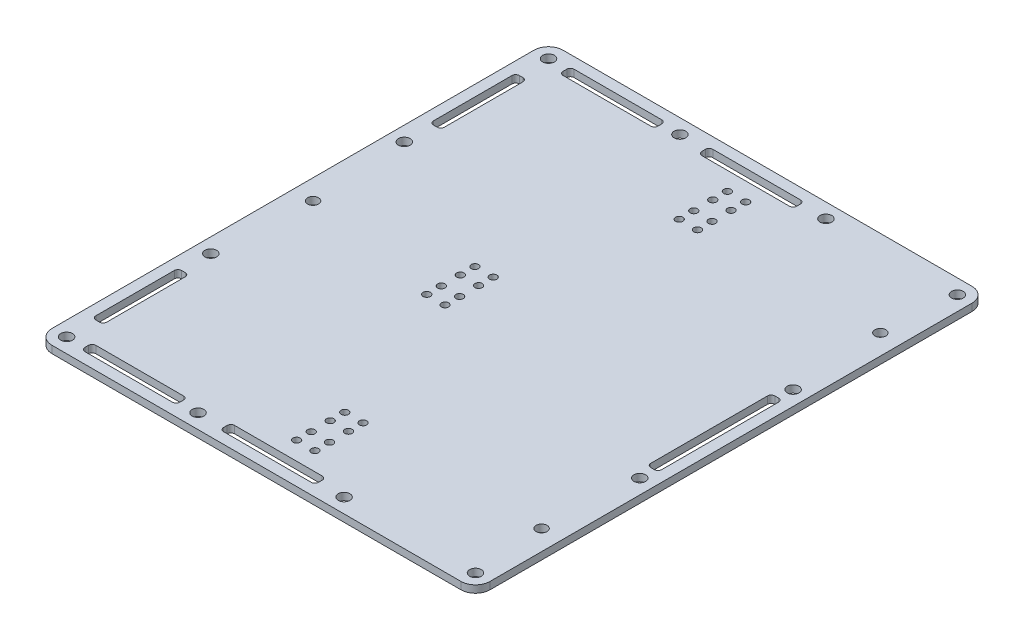
from build123d import *

# Parameters (mm, degrees)
SKETCH1_W           = 120
SKETCH1_H           = 140
BOSS_EXTRUDE1_DEPTH = 4
SKETCH20_W          = 20
SKETCH20_H          = 3
BOSS_EXTRUDE5_DEPTH = 8
SKETCH25_R          = 1.6
CUT_EXTRUDE21_DEPTH = 142.061724079
CUT_EXTRUDE22_DEPTH = 10
SKETCH15_R          = 1.6
CUT_EXTRUDE24_DEPTH = 93.54188241
SKETCH28_W          = 120
SKETCH28_H          = 12
CUT_EXTRUDE25_DEPTH = 153.787434038
SKETCH26_W          = 20
SKETCH26_H          = 62
SKETCH26_H_2        = 27
BOSS_EXTRUDE6_DEPTH = 8
CUT_EXTRUDE32_DEPTH = 30
CUT_EXTRUDE33_DEPTH = 30
SKETCH30_R          = 1
CUT_EXTRUDE34_DEPTH = 93.736184955
CUT_EXTRUDE35_DEPTH = 118.749734607
SKETCH33_W          = 20
SKETCH33_H          = 10.5
SKETCH33_H_2        = 29
CUT_EXTRUDE36_DEPTH = 8
CUT_EXTRUDE37_DEPTH = 93.736184955
FILLET1_R           = 0.5
SKETCH35_R          = 1.5
CUT_EXTRUDE38_DEPTH = 10


with BuildPart() as part:
    # Sketch1 → Boss-Extrude1 (new body)
    with BuildSketch(Plane(origin=(0, 0, 0), x_dir=(1, 0, 0), z_dir=(0, 1, 0))):
        Rectangle(SKETCH1_W, SKETCH1_H)
    extrude(amount=BOSS_EXTRUDE1_DEPTH)

    # Sketch20 → Boss-Extrude5 (add)
    with BuildSketch(Plane(origin=(0, 4, 0), x_dir=(1, 0, 0), z_dir=(0, 1, 0))):
        with Locations((-42.5, -55.6)):
            Rectangle(SKETCH20_W, SKETCH20_H)
        with Locations((-42.5, -35.6)):
            Rectangle(SKETCH20_W, SKETCH20_H)
        with Locations((42.5, -10)):
            Rectangle(SKETCH20_W, SKETCH20_H)
        with Locations((42.5, 10)):
            Rectangle(SKETCH20_W, SKETCH20_H)
        with Locations((-42.5, 55.6)):
            Rectangle(SKETCH20_W, SKETCH20_H)
        with Locations((-42.5, 35.6)):
            Rectangle(SKETCH20_W, SKETCH20_H)
    extrude(amount=BOSS_EXTRUDE5_DEPTH)

    # Sketch25 → Cut-Extrude21 (cut, through all)
    with BuildSketch(Plane.XY.offset(57.1)):
        with Locations((-47.5, 8)):
            Circle(SKETCH25_R)
        with Locations((-37.5, 8)):
            Circle(SKETCH25_R)
        with Locations((37.5, 8)):
            Circle(SKETCH25_R)
        with Locations((47.5, 8)):
            Circle(SKETCH25_R)
    extrude(amount=-CUT_EXTRUDE21_DEPTH, mode=Mode.SUBTRACT)

    # Sketch9 → Cut-Extrude22 (cut)
    with BuildSketch(Plane(origin=(0, 4, 0), x_dir=(1, 0, 0), z_dir=(0, 1, 0))):
        with BuildLine():
            Line((-60, -70), (-56, -70))
            ThreePointArc((-56, -70), (-58.828427125, -68.828427125), (-60, -66))
            Line((-60, -66), (-60, -70))
        make_face()
        with BuildLine():
            ThreePointArc((60, -66), (58.828427125, -68.828427125), (56, -70))
            Line((56, -70), (60, -70))
            Line((60, -70), (60, -66))
        make_face()
        with BuildLine():
            Line((-60, 70), (-60, 66))
            ThreePointArc((-60, 66), (-58.828427125, 68.828427125), (-56, 70))
            Line((-56, 70), (-60, 70))
        make_face()
        with BuildLine():
            ThreePointArc((56, 70), (58.828427125, 68.828427125), (60, 66))
            Line((60, 66), (60, 70))
            Line((60, 70), (56, 70))
        make_face()
    extrude(amount=-CUT_EXTRUDE22_DEPTH, mode=Mode.SUBTRACT)

    # Sketch15 → Cut-Extrude24 (cut, through all)
    with BuildSketch(Plane(origin=(0, 4, 0), x_dir=(1, 0, 0), z_dir=(0, 1, 0))):
        with Locations((-56, 66)):
            Circle(SKETCH15_R)
        with Locations((-56, -66)):
            Circle(SKETCH15_R)
        with Locations((56, -66)):
            Circle(SKETCH15_R)
        with Locations((56, 66)):
            Circle(SKETCH15_R)
        with Locations((-56, -26.5)):
            Circle(SKETCH15_R)
        with Locations((-56, 26.5)):
            Circle(SKETCH15_R)
        with Locations((20, 66)):
            Circle(SKETCH15_R)
        with Locations((-20, 66)):
            Circle(SKETCH15_R)
        with Locations((-20, -66)):
            Circle(SKETCH15_R)
        with Locations((20, -66)):
            Circle(SKETCH15_R)
        with Locations((56, -21)):
            Circle(SKETCH15_R)
        with Locations((56, 21)):
            Circle(SKETCH15_R)
    extrude(amount=-CUT_EXTRUDE24_DEPTH, mode=Mode.SUBTRACT)

    # Sketch28 → Cut-Extrude25 (cut, through all)
    with BuildSketch(Plane.XY.offset(70)):
        with Locations((0, 8)):
            Rectangle(SKETCH28_W, SKETCH28_H)
    extrude(amount=-CUT_EXTRUDE25_DEPTH, mode=Mode.SUBTRACT)

    # Sketch26 → Boss-Extrude6 (add)
    with BuildSketch(Plane.XZ):
        with Locations((35, 0)):
            Rectangle(SKETCH26_W, SKETCH26_H)
        with Locations((5, 0)):
            Rectangle(SKETCH26_W, SKETCH26_H)
        with Locations((-40, 38.5)):
            Rectangle(SKETCH26_W, SKETCH26_H_2)
        with Locations((-25, -38.5)):
            Rectangle(SKETCH26_W, SKETCH26_H_2)
    extrude(amount=BOSS_EXTRUDE6_DEPTH)

    # Sketch31 → Cut-Extrude32 (cut)
    with BuildSketch(Plane(origin=(0, 0, -52), x_dir=(-1, 0, 0), z_dir=(0, 0, -1))):
        with BuildLine():
            Line((17.7, -4.4), (17.7, -3.4))
            ThreePointArc((17.7, -3.4), (19.9, -1.2), (22.1, -3.4))
            Line((22.1, -3.4), (22.1, -4.4))
            ThreePointArc((22.1, -4.4), (19.9, -6.6), (17.7, -4.4))
        make_face()
        with BuildLine():
            Line((27.9, -4.4), (27.9, -3.4))
            ThreePointArc((27.9, -3.4), (30.1, -1.2), (32.3, -3.4))
            Line((32.3, -3.4), (32.3, -4.4))
            ThreePointArc((32.3, -4.4), (30.1, -6.6), (27.9, -4.4))
        make_face()
    extrude(amount=-CUT_EXTRUDE32_DEPTH, mode=Mode.SUBTRACT)

    # Sketch32 → Cut-Extrude33 (cut)
    with BuildSketch(Plane.XY.offset(52)):
        with BuildLine():
            Line((-47.3, -4.4), (-47.3, -3.4))
            ThreePointArc((-47.3, -3.4), (-45.1, -1.2), (-42.9, -3.4))
            Line((-42.9, -3.4), (-42.9, -4.4))
            ThreePointArc((-42.9, -4.4), (-45.1, -6.6), (-47.3, -4.4))
        make_face()
        with BuildLine():
            Line((-37.1, -4.4), (-37.1, -3.4))
            ThreePointArc((-37.1, -3.4), (-34.9, -1.2), (-32.7, -3.4))
            Line((-32.7, -3.4), (-32.7, -4.4))
            ThreePointArc((-32.7, -4.4), (-34.9, -6.6), (-37.1, -4.4))
        make_face()
    extrude(amount=-CUT_EXTRUDE33_DEPTH, mode=Mode.SUBTRACT)

    # Sketch30 → Cut-Extrude34 (cut, through all)
    with BuildSketch(Plane(origin=(0, 2, 0), x_dir=(1, 0, 0), z_dir=(0, 1, 0))):
        with Locations((5, 59)):
            Circle(SKETCH30_R)
        with Locations((5, 49.8)):
            Circle(SKETCH30_R)
        with Locations((5, 45.8)):
            Circle(SKETCH30_R)
        with Locations((5, 55)):
            Circle(SKETCH30_R)
        with Locations((5, -49.8)):
            Circle(SKETCH30_R)
        with Locations((5, -55)):
            Circle(SKETCH30_R)
        with Locations((5, -45.8)):
            Circle(SKETCH30_R)
        with Locations((5, -59)):
            Circle(SKETCH30_R)
        with Locations((0, -49.8)):
            Circle(SKETCH30_R)
        with Locations((0, -55)):
            Circle(SKETCH30_R)
        with Locations((0, -45.8)):
            Circle(SKETCH30_R)
        with Locations((0, -59)):
            Circle(SKETCH30_R)
        with Locations((0, 59)):
            Circle(SKETCH30_R)
        with Locations((0, 45.8)):
            Circle(SKETCH30_R)
        with Locations((0, 55)):
            Circle(SKETCH30_R)
        with Locations((0, 49.8)):
            Circle(SKETCH30_R)
        with Locations((-11.75, 2.6)):
            Circle(SKETCH30_R)
        with Locations((-11.75, -2.6)):
            Circle(SKETCH30_R)
        with Locations((-11.75, 6.6)):
            Circle(SKETCH30_R)
        with Locations((-11.75, -6.6)):
            Circle(SKETCH30_R)
        with Locations((-16.75, 2.6)):
            Circle(SKETCH30_R)
        with Locations((-16.75, -2.6)):
            Circle(SKETCH30_R)
        with Locations((-16.75, 6.6)):
            Circle(SKETCH30_R)
        with Locations((-16.75, -6.6)):
            Circle(SKETCH30_R)
    extrude(amount=-CUT_EXTRUDE34_DEPTH, mode=Mode.SUBTRACT)

    # Sketch29 → Cut-Extrude35 (cut, through all)
    with BuildSketch(Plane(origin=(0, 0, -31), x_dir=(-1, 0, 0), z_dir=(0, 0, -1))):
        with BuildLine():
            Line((-7.9, -3.4), (-7.9, -4.4))
            ThreePointArc((-7.9, -4.4), (-10.1, -6.6), (-12.3, -4.4))
            Line((-12.3, -4.4), (-12.3, -3.4))
            ThreePointArc((-12.3, -3.4), (-10.1, -1.2), (-7.9, -3.4))
        make_face()
        with BuildLine():
            Line((-37.9, -3.4), (-37.9, -4.4))
            ThreePointArc((-37.9, -4.4), (-40.1, -6.6), (-42.3, -4.4))
            Line((-42.3, -4.4), (-42.3, -3.4))
            ThreePointArc((-42.3, -3.4), (-40.1, -1.2), (-37.9, -3.4))
        make_face()
        with BuildLine():
            Line((-27.7, -3.4), (-27.7, -4.4))
            ThreePointArc((-27.7, -4.4), (-29.9, -6.6), (-32.1, -4.4))
            Line((-32.1, -4.4), (-32.1, -3.4))
            ThreePointArc((-32.1, -3.4), (-29.9, -1.2), (-27.7, -3.4))
        make_face()
        with BuildLine():
            Line((2.3, -3.4), (2.3, -4.4))
            ThreePointArc((2.3, -4.4), (0.1, -6.6), (-2.1, -4.4))
            Line((-2.1, -4.4), (-2.1, -3.4))
            ThreePointArc((-2.1, -3.4), (0.1, -1.2), (2.3, -3.4))
        make_face()
    extrude(amount=-CUT_EXTRUDE35_DEPTH, mode=Mode.SUBTRACT)

    # Sketch33 → Cut-Extrude36 (cut)
    with BuildSketch(Plane.XZ.offset(8)):
        with Locations((-25, -46.75)):
            Rectangle(SKETCH33_W, SKETCH33_H)
        with Locations((35, 0)):
            Rectangle(SKETCH33_W, SKETCH33_H_2)
    extrude(amount=-CUT_EXTRUDE36_DEPTH, mode=Mode.SUBTRACT)

    # Sketch34 → Cut-Extrude37 (cut, through all)
    with BuildSketch(Plane(origin=(0, 2, 0), x_dir=(1, 0, 0), z_dir=(0, 1, 0))):
        with BuildLine():
            Line((-50, -64), (-26, -64))
            ThreePointArc((-26, -64), (-25.292893219, -64.292893219), (-25, -65))
            Line((-25, -65), (-25, -66))
            ThreePointArc((-25, -66), (-25.292893219, -66.707106781), (-26, -67))
            Line((-26, -67), (-50, -67))
            ThreePointArc((-50, -67), (-50.707106781, -66.707106781), (-51, -66))
            Line((-51, -66), (-51, -65))
            ThreePointArc((-51, -65), (-50.707106781, -64.292893219), (-50, -64))
        make_face()
        with BuildLine():
            Line((-56, -34.5), (-55, -34.5))
            ThreePointArc((-55, -34.5), (-54.292893219, -34.792893219), (-54, -35.5))
            Line((-54, -35.5), (-54, -57))
            ThreePointArc((-54, -57), (-54.292893219, -57.707106781), (-55, -58))
            Line((-55, -58), (-56, -58))
            ThreePointArc((-56, -58), (-56.707106781, -57.707106781), (-57, -57))
            Line((-57, -57), (-57, -35.5))
            ThreePointArc((-57, -35.5), (-56.707106781, -34.792893219), (-56, -34.5))
        make_face()
        with BuildLine():
            Line((-12, -64), (12, -64))
            ThreePointArc((12, -64), (12.707106781, -64.292893219), (13, -65))
            Line((13, -65), (13, -66))
            ThreePointArc((13, -66), (12.707106781, -66.707106781), (12, -67))
            Line((12, -67), (-12, -67))
            ThreePointArc((-12, -67), (-12.707106781, -66.707106781), (-13, -66))
            Line((-13, -66), (-13, -65))
            ThreePointArc((-13, -65), (-12.707106781, -64.292893219), (-12, -64))
        make_face()
        with BuildLine():
            Line((55, 17), (56, 17))
            ThreePointArc((56, 17), (56.707106781, 16.707106781), (57, 16))
            Line((57, 16), (57, -16))
            ThreePointArc((57, -16), (56.707106781, -16.707106781), (56, -17))
            Line((56, -17), (55, -17))
            ThreePointArc((55, -17), (54.292893219, -16.707106781), (54, -16))
            Line((54, -16), (54, 16))
            ThreePointArc((54, 16), (54.292893219, 16.707106781), (55, 17))
        make_face()
    cut_extrude37 = extrude(amount=-CUT_EXTRUDE37_DEPTH, mode=Mode.SUBTRACT)

    # Mirror1: Cut-Extrude37 across plane
    add(cut_extrude37.mirror(Plane.XY), mode=Mode.SUBTRACT)

    # Fillet1
    fillet1_edges = [part.edges().sort_by_distance(p)[0] for p in [
        (4, 0, -59),
        (-1, 0, -59),
        (-1, 0, -55),
        (4, 0, -55),
        (4, 0, -49.8),
        (-1, 0, -49.8),
        (-1, 0, -45.8),
        (4, 0, -45.8),
        (-12.75, 0, -6.6),
        (-17.75, 0, -6.6),
        (-17.75, 0, -2.6),
        (-12.75, 0, -2.6),
        (-12.75, 0, 2.6),
        (-17.75, 0, 2.6),
        (-17.75, 0, 6.6),
        (-12.75, 0, 6.6),
        (-1, 0, 45.8),
        (4, 0, 45.8),
        (4, 0, 49.8),
        (-1, 0, 49.8),
        (4, 0, 55),
        (-1, 0, 55),
        (4, 0, 59),
        (-1, 0, 59),
    ]]
    fillet(fillet1_edges, radius=FILLET1_R)

    # Sketch35 → Cut-Extrude38 (cut)
    with BuildSketch(Plane.XZ):
        with Locations((54.5, -46.4)):
            Circle(SKETCH35_R)
        with Locations((-54.5, 0)):
            Circle(SKETCH35_R)
        with Locations((54.5, 46.4)):
            Circle(SKETCH35_R)
    extrude(amount=-CUT_EXTRUDE38_DEPTH, mode=Mode.SUBTRACT)


solid = part.part
